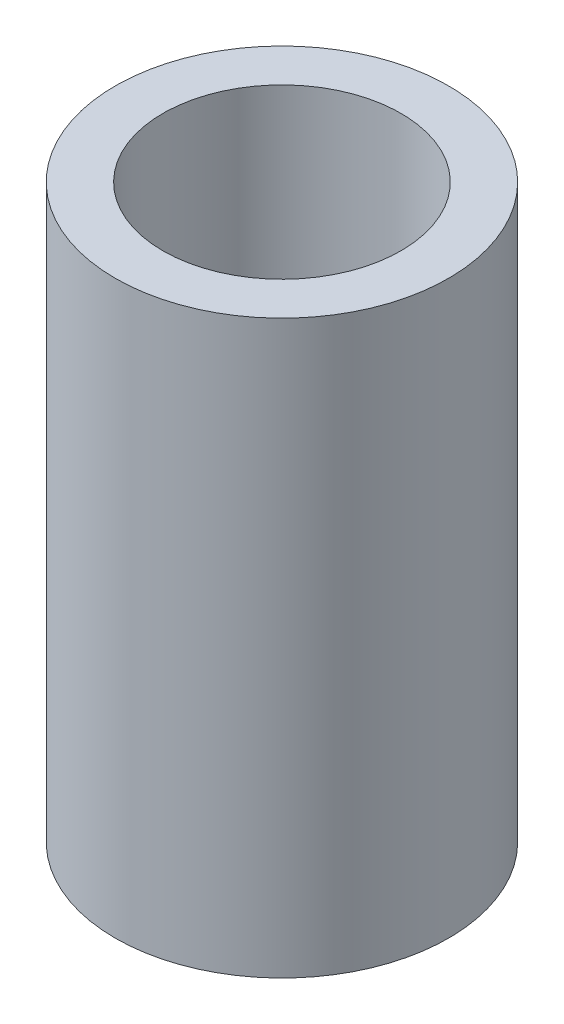
from build123d import *

# Parameters (mm, degrees)
SKETCH1_R           = 11.1125
SKETCH1_R_2         = 7.9375
BOSS_EXTRUDE1_DEPTH = 38.1


with BuildPart() as part:
    # Sketch1 → Boss-Extrude1 (new body)
    with BuildSketch(Plane(origin=(0, 0, 0), x_dir=(1, 0, 0), z_dir=(0, 1, 0))):
        Circle(SKETCH1_R)
        Circle(SKETCH1_R_2, mode=Mode.SUBTRACT)
    extrude(amount=BOSS_EXTRUDE1_DEPTH)


solid = part.part
